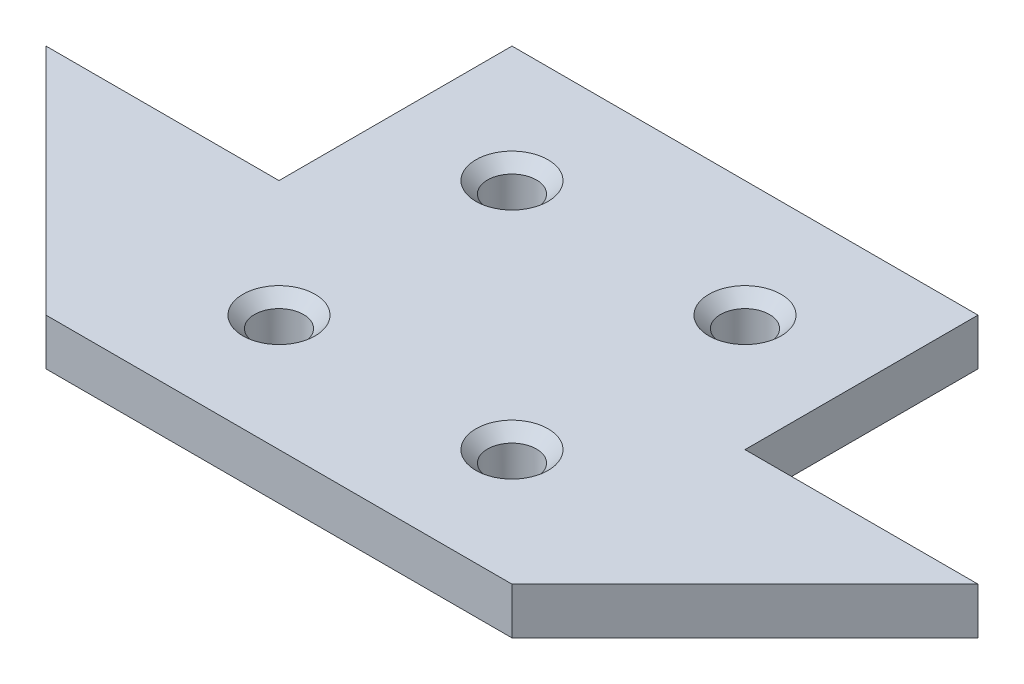
from build123d import *

# Parameters (mm, degrees)
BOSS_EXTRUDE1_DEPTH = 4
SKETCH2_R           = 2.1
CUT_EXTRUDE1_DEPTH  = 4
CHAMFER1_SIZE       = 1


with BuildPart() as part:
    # Sketch1 → Boss-Extrude1 (new body)
    with BuildSketch(Plane(origin=(0, 0, 0), x_dir=(1, 0, 0), z_dir=(0, 1, 0))):
        Polygon((-4.540045767, -33.235697941), (35.459954233, -33.235697941), (55.459954233, -13.235697941), (35.459954233, -13.235697941), (35.459954233, 6.764302059), (-4.540045767, 6.764302059), (-4.540045767, -13.235697941), (-24.540045767, -13.235697941), align=None)
    extrude(amount=BOSS_EXTRUDE1_DEPTH)

    # Sketch2 → Cut-Extrude1 (cut)
    with BuildSketch(Plane(origin=(0, 4, 0), x_dir=(1, 0, 0), z_dir=(0, 1, 0))):
        with Locations((5.459954233, -23.235697941)):
            Circle(SKETCH2_R)
        with Locations((25.459954233, -23.235697941)):
            Circle(SKETCH2_R)
        with Locations((25.459954233, -3.235697941)):
            Circle(SKETCH2_R)
        with Locations((5.459954233, -3.235697941)):
            Circle(SKETCH2_R)
    extrude(amount=-CUT_EXTRUDE1_DEPTH, mode=Mode.SUBTRACT)

    # Chamfer1
    chamfer1_edges = [part.edges().sort_by_distance(p)[0] for p in [
        (3.359954233, 4, 3.235697941),
        (23.359954233, 4, 3.235697941),
        (23.359954233, 4, 23.235697941),
        (3.359954233, 4, 23.235697941),
    ]]
    chamfer(chamfer1_edges, length=CHAMFER1_SIZE)


solid = part.part
